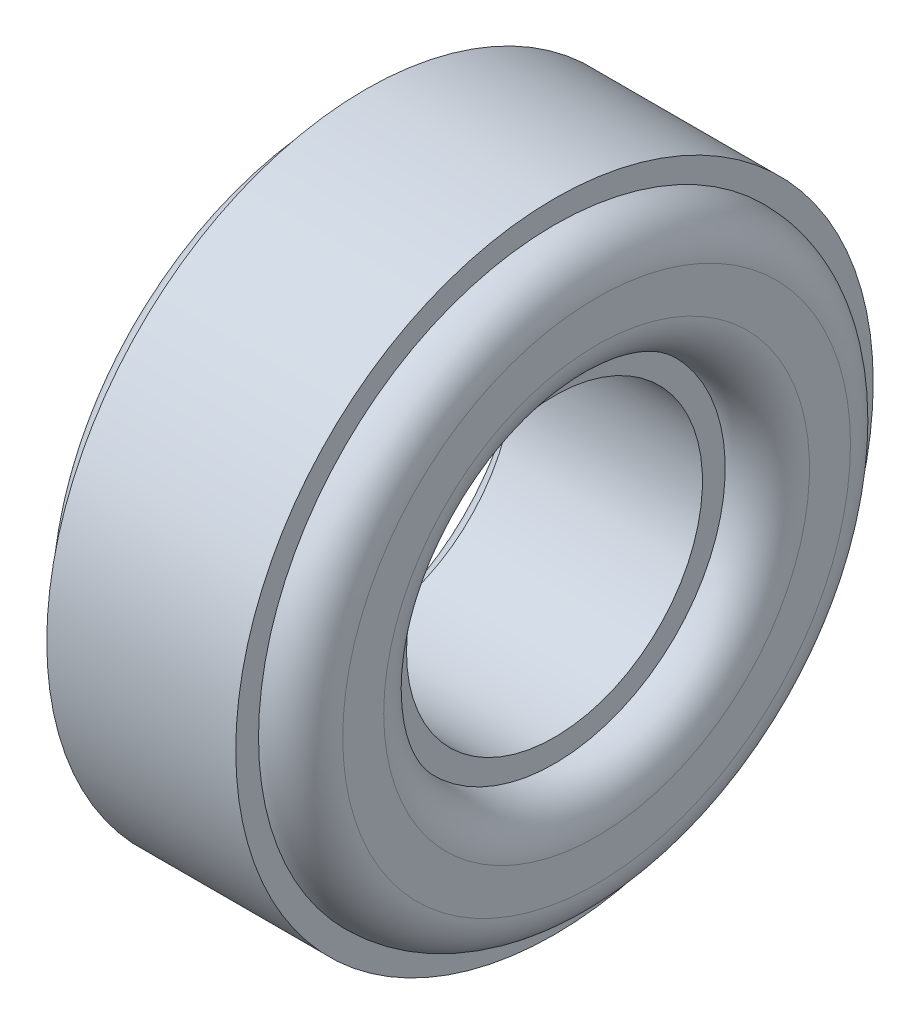
from build123d import *


with BuildPart() as part:
    # Sketch1 → Revolve1 (revolve)
    with BuildSketch(Plane.XY):
        with BuildLine():
            Line((10.15, 9.35), (10.15, 11.15))
            ThreePointArc((10.15, 11.15), (9.608147545, 12.458147545), (8.3, 13))
            Line((8.3, 13), (8.3, 14))
            Line((8.3, 14), (0, 14))
            Line((0, 14), (0, 13))
            ThreePointArc((0, 13), (-1.308147545, 12.458147545), (-1.85, 11.15))
            Line((-1.85, 11.15), (-1.85, 9.35))
            ThreePointArc((-1.85, 9.35), (-1.308147545, 8.041852455), (0, 7.5))
            Line((0, 7.5), (0, 6.5))
            Line((0, 6.5), (8.3, 6.5))
            Line((8.3, 6.5), (8.3, 7.5))
            ThreePointArc((8.3, 7.5), (9.608147545, 8.041852455), (10.15, 9.35))
        make_face()
    revolve(axis=Axis((-8.833016473, 0, 0), (1, 0, 0)))


solid = part.part
